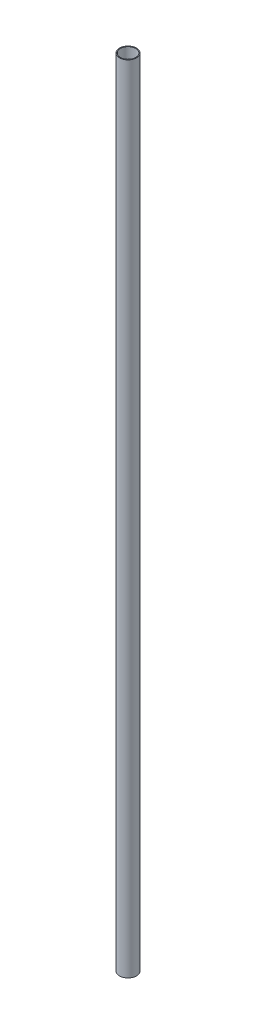
from build123d import *

# Parameters (mm, degrees)
SKETCH1_R           = 9.525
SKETCH1_R_2         = 8.636
BOSS_EXTRUDE1_DEPTH = 889


with BuildPart() as part:
    # Sketch1 → Boss-Extrude1 (new body)
    with BuildSketch(Plane(origin=(0, 0, 0), x_dir=(1, 0, 0), z_dir=(0, 1, 0))):
        Circle(SKETCH1_R)
        Circle(SKETCH1_R_2, mode=Mode.SUBTRACT)
    extrude(amount=BOSS_EXTRUDE1_DEPTH)


solid = part.part
